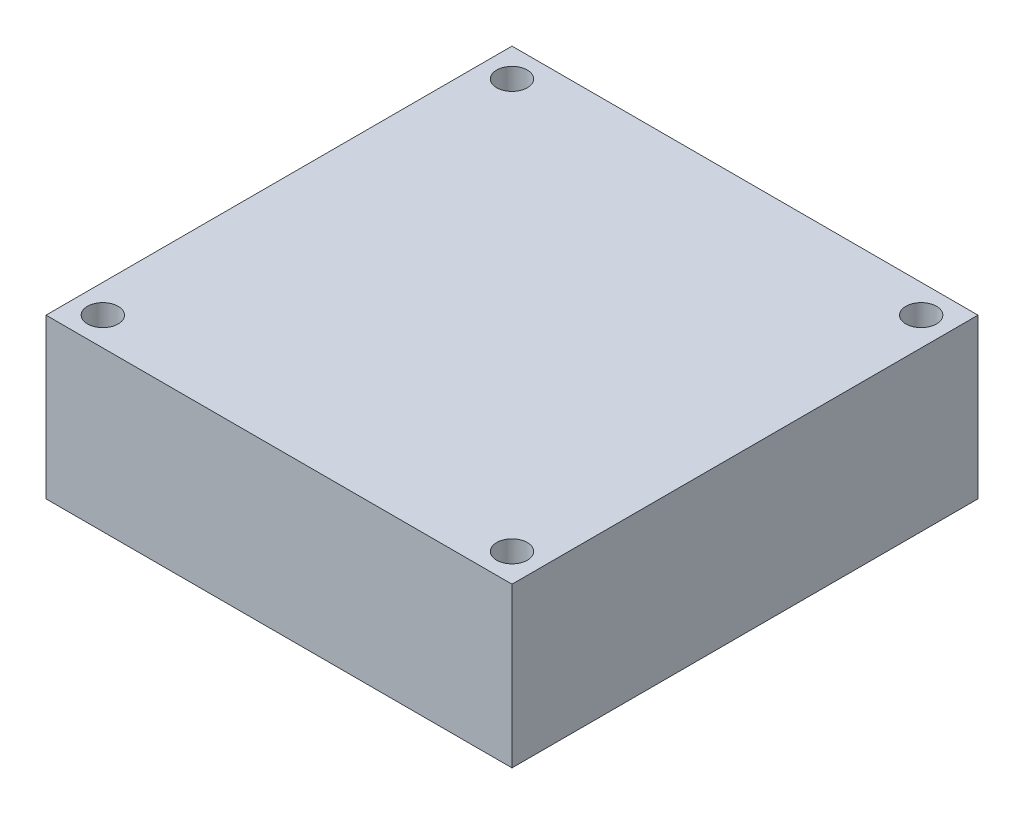
from build123d import *

# Parameters (mm, degrees)
SKETCH_1_W          = 41
SKETCH_1_H          = 41
EXTRUDE_1_DEPTH     = 14
SKETCH_2_R          = 1.35
CUT_EXTRUDE_1_DEPTH = 14


with BuildPart() as part:
    # 草图1 → 凸台-拉伸1 (new body)
    with BuildSketch(Plane(origin=(0, 0, 0), x_dir=(1, 0, 0), z_dir=(0, 1, 0))):
        Rectangle(SKETCH_1_W, SKETCH_1_H)
    extrude(amount=EXTRUDE_1_DEPTH)

    # 草图2 → 切除-拉伸1 (cut)
    with BuildSketch(Plane(origin=(0, 14, 0), x_dir=(1, 0, 0), z_dir=(0, 1, 0))):
        with Locations((-18, 18)):
            Circle(SKETCH_2_R)
        with Locations((18, 18)):
            Circle(SKETCH_2_R)
        with Locations((18, -18)):
            Circle(SKETCH_2_R)
        with Locations((-18, -18)):
            Circle(SKETCH_2_R)
    extrude(amount=-CUT_EXTRUDE_1_DEPTH, mode=Mode.SUBTRACT)


solid = part.part
